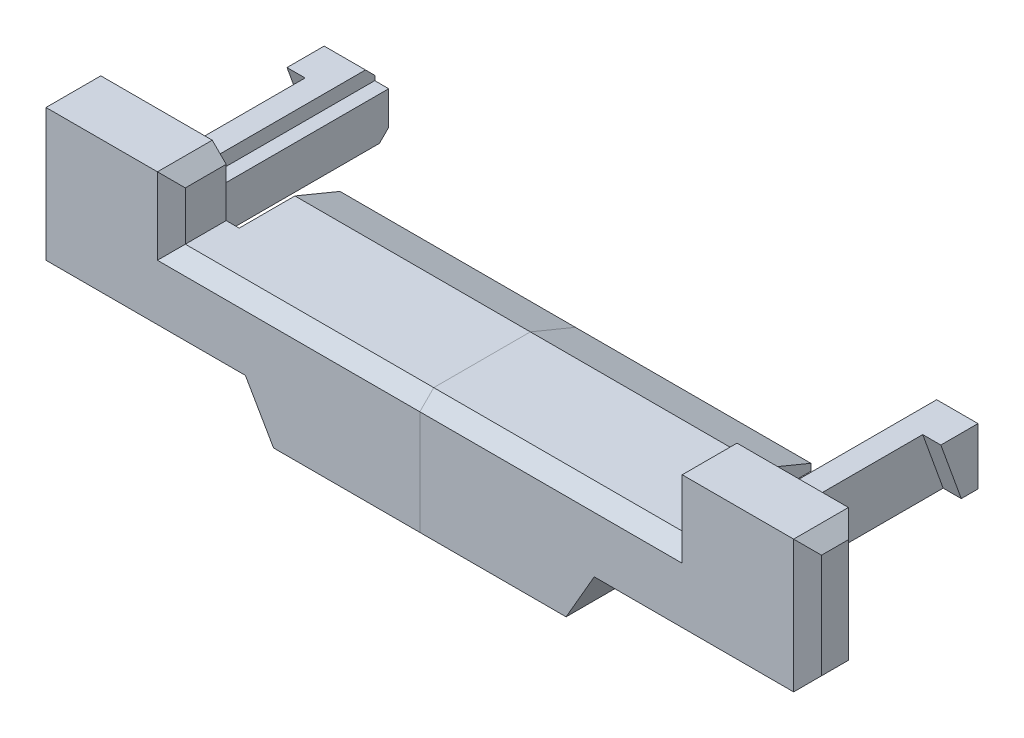
from build123d import *

# Parameters (mm, degrees)
BOSS_EXTRUDE1_DEPTH        = 1.18
SKETCH2_W                  = 15.84
SKETCH2_H                  = 2.17
BOSS_EXTRUDE2_DEPTH        = 0.55
CUT_EXTRUDE1_DEPTH         = 20.341297785
CUT_EXTRUDE1_DEPTH_BACK    = 20.341297785
CHAMFER1_SIZE              = 0.3
CHAMFER2_SIZE              = 0.3
SKETCH4_W                  = 1.19
SKETCH4_H                  = 1.22
BOSS_EXTRUDE3_DEPTH        = 4
SKETCH5_W                  = 0.3
SKETCH5_H                  = 0.3
CUT_EXTRUDE2_DEPTH         = 4
CHAMFER3_SIZE              = 0.2
CUT_EXTRUDE3_DEPTH         = 0.39
SZKIC1_W                   = 5.7
SZKIC1_H                   = 6.96
WYTNIJ_WYCI_GNI_CIE1_DEPTH = 13.163161596


with BuildPart() as part:
    # Sketch1 → Boss-Extrude1 (new body)
    with BuildSketch(Plane.XY):
        Polygon((-8.2, 0.6), (-8.2, 1.95), (-11.2, 1.95), (-11.2, -0.9), (-6.606217783, -0.9), (-6, -1.95), (6, -1.95), (6.606217783, -0.9), (11.2, -0.9), (11.2, 1.95), (8.2, 1.95), (8.2, 0.6), align=None)
    extrude(amount=BOSS_EXTRUDE1_DEPTH)

    # Sketch2 → Boss-Extrude2 (add)
    with BuildSketch(Plane(origin=(0, 0.6, 0), x_dir=(1, 0, 0), z_dir=(0, 1, 0))):
        with Locations((0, 1.085)):
            Rectangle(SKETCH2_W, SKETCH2_H)
    extrude(amount=-BOSS_EXTRUDE2_DEPTH)

    # Sketch3 → Cut-Extrude1 (cut, two sides)
    with BuildSketch(Plane.ZY.offset(7.92)) as cut_extrude1_sk:
        Polygon((-1.2, 0.6), (-2.17, 0.2), (-2.17, 0.6), align=None)
    extrude(amount=CUT_EXTRUDE1_DEPTH, mode=Mode.SUBTRACT)
    extrude(cut_extrude1_sk.sketch, amount=-CUT_EXTRUDE1_DEPTH_BACK, mode=Mode.SUBTRACT)

    # Chamfer1
    chamfer1_edges = [part.edges().sort_by_distance(p)[0] for p in [
        (11.2, 0.525, 0),
        (-11.2, 0.525, 1.18),
        (-11.2, 0.525, 0),
        (11.2, 1.95, 0.59),
        (11.2, -0.9, 0.59),
        (-11.2, -0.9, 0.59),
        (-11.2, 1.95, 0.59),
        (11.2, 0.525, 1.18),
    ]]
    chamfer(chamfer1_edges, length=CHAMFER1_SIZE)

    # Chamfer2
    chamfer2_edges = [part.edges().sort_by_distance(p)[0] for p in [
        (8.2, 1.95, 0.59),
        (-8.2, 1.95, 0.59),
        (8.2, 1.275, 1.18),
        (0, 0.6, 1.18),
        (-8.2, 1.275, 1.18),
    ]]
    chamfer(chamfer2_edges, length=CHAMFER2_SIZE)

    # Szkic1 → Wytnij-wyciągnięcie1 (cut, through all)
    with BuildSketch(Plane(origin=(0, 0.6, 0), x_dir=(1, 0, 0), z_dir=(0, 1, 0))):
        Rectangle(SZKIC1_W, SZKIC1_H)
    extrude(amount=-WYTNIJ_WYCI_GNI_CIE1_DEPTH, mode=Mode.SUBTRACT)


with BuildPart() as body_2:
    # Sketch4 → Boss-Extrude3 (new body)
    with BuildSketch(Plane(origin=(0, 0, 0), x_dir=(-1, 0, 0), z_dir=(0, 0, -1))):
        with Locations((-9.295, 0.5)):
            Rectangle(SKETCH4_W, SKETCH4_H)
    extrude(amount=BOSS_EXTRUDE3_DEPTH)

    # Sketch5 → Cut-Extrude2 (cut)
    with BuildSketch(Plane(origin=(0, 0, -4), x_dir=(-1, 0, 0), z_dir=(0, 0, -1))):
        with Locations((-8.85, 0.96)):
            Rectangle(SKETCH5_W, SKETCH5_H)
    extrude(amount=-CUT_EXTRUDE2_DEPTH, mode=Mode.SUBTRACT)

    # Chamfer3
    chamfer3_edges = [body_2.edges().sort_by_distance(p)[0] for p in [
        (9.89, 0.5, -4),
        (9.295, -0.11, -4),
        (9.445, 1.11, -4),
    ]]
    chamfer(chamfer3_edges, length=CHAMFER3_SIZE)

    # Sketch6 → Cut-Extrude3 (cut)
    with BuildSketch(Plane(origin=(9.89, 0, 0), x_dir=(0, 0, -1), z_dir=(1, 0, 0))):
        Polygon((3.44, -0.11), (3, 1.11), (0, 1.11), (0, -0.11), align=None)
    extrude(amount=-CUT_EXTRUDE3_DEPTH, mode=Mode.SUBTRACT)


with BuildPart() as body_3:
    # Mirror1: mirrored copy
    add(body_2.part.mirror(Plane(origin=(0, 0, 0), x_dir=(0, 0, 1), z_dir=(1, 0, 0))))


with BuildPart() as wytnij_wyci_gni_cie1_piece_1:
    # of the separate pieces the step leaves, piece 1, a body of its own (wytnij_wyci_gni_cie1_pieces)
    add(part.part.solids().sort_by_distance((8.5, 1.95, 0))[0])


with BuildPart() as wytnij_wyci_gni_cie1_piece_2:
    # of the separate pieces the step leaves, piece 2, a body of its own (wytnij_wyci_gni_cie1_pieces)
    add(part.part.solids().sort_by_distance((-8.5, 1.95, 0))[0])


with BuildPart() as wytnij_wyci_gni_cie1_piece_1_1:
    # Obiekt-Przenieś/Kopiuj1: moved
    add(wytnij_wyci_gni_cie1_piece_1.part.moved(Location((-5.7, 0, 0))))


with BuildPart() as body_2_1:
    # Obiekt-Przenieś/Kopiuj1: moved
    add(body_2.part.moved(Location((-5.7, 0, 0))))


solid = Compound([body_3.part, wytnij_wyci_gni_cie1_piece_2.part, wytnij_wyci_gni_cie1_piece_1_1.part, body_2_1.part])
